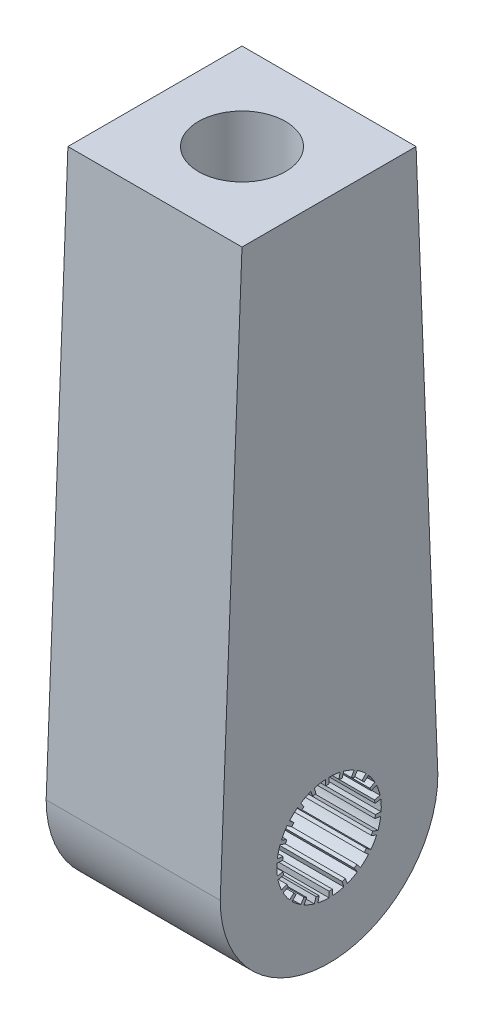
from build123d import *

# Parameters (mm, degrees)
SKETCH1_R           = 6
BOSS_EXTRUDE1_DEPTH = 20
SKETCH2_R           = 5
CUT_EXTRUDE1_DEPTH  = 50
BOSS_EXTRUDE2_DEPTH = 20


with BuildPart() as part:
    # Sketch1 → Boss-Extrude1 (new body)
    with BuildSketch(Plane(origin=(0, 0, 0), x_dir=(0, 0, -1), z_dir=(1, 0, 0))):
        with BuildLine():
            Line((10, 63.75), (0, 63.75))
            Line((0, 63.75), (-10, 63.75))
            Line((-10, 63.75), (-12.461612284, 0.978886756))
            Line((-12.461612284, 0.978886756), (-12.5, 0))
            ThreePointArc((-12.5, 0), (0, -12.5), (12.5, 0))
            Line((12.5, 0), (12.461612284, 0.978886756))
            Line((12.461612284, 0.978886756), (10, 63.75))
        make_face()
        Circle(SKETCH1_R, mode=Mode.SUBTRACT)
    extrude(amount=BOSS_EXTRUDE1_DEPTH)

    # Sketch2 → Cut-Extrude1 (cut)
    with BuildSketch(Plane(origin=(0, 63.75, 0), x_dir=(1, 0, 0), z_dir=(0, 1, 0))):
        with Locations(Location((10, 0, 0), (0, 0, 270))):
            Circle(SKETCH2_R)
    extrude(amount=-CUT_EXTRUDE1_DEPTH, mode=Mode.SUBTRACT)

    # Sketch3 → Boss-Extrude2 (add)
    with BuildSketch(Plane(origin=(20, 0, 0), x_dir=(0, 0, -1), z_dir=(1, 0, 0))):
        with BuildLine():
            ThreePointArc((0, 6), (-0.214106434, 5.996178653), (-0.427940142, 5.984719478))
            Line((-0.427940142, 5.984719478), (-0.380866727, 5.326400336))
            ThreePointArc((-0.380866727, 5.326400336), (-0.190554726, 5.336599001), (0, 5.34))
            Line((0, 5.34), (0, 6))
        make_face()
        with BuildLine():
            Line((-1.504451854, 5.123692479), (-1.690395341, 5.756957842))
            ThreePointArc((-1.690395341, 5.756957842), (-1.894752362, 5.692970533), (-2.09669588, 5.621731618))
            Line((-2.09669588, 5.621731618), (-1.866059333, 5.00334114))
            ThreePointArc((-1.866059333, 5.00334114), (-1.686329602, 5.066743774), (-1.504451854, 5.123692479))
        make_face()
        with BuildLine():
            ThreePointArc((1.690395341, 5.756957842), (1.483885124, 5.813612039), (1.275484761, 5.862860959))
            Line((1.275484761, 5.862860959), (1.135181437, 5.217946254))
            ThreePointArc((1.135181437, 5.217946254), (1.320657761, 5.174114715), (1.504451853, 5.123692479))
            Line((1.504451853, 5.123692479), (1.690395341, 5.756957842))
        make_face()
        with BuildLine():
            Line((-2.887021965, 4.492293865), (-3.243844905, 5.047521197))
            ThreePointArc((-3.243844905, 5.047521197), (-3.421896722, 4.928551798), (-3.595589788, 4.803304496))
            Line((-3.595589788, 4.803304496), (-3.200074911, 4.274941001))
            ThreePointArc((-3.200074911, 4.274941001), (-3.045488083, 4.3864111), (-2.887021965, 4.492293865))
        make_face()
        with BuildLine():
            ThreePointArc((3.243844904, 5.047521197), (3.061661135, 5.160061152), (2.875577474, 5.266028313))
            Line((2.875577474, 5.266028313), (2.559263952, 4.686765198))
            ThreePointArc((2.559263952, 4.686765198), (2.72487841, 4.592454426), (2.887021965, 4.492293866))
            Line((2.887021965, 4.492293866), (3.243844904, 5.047521197))
        make_face()
        with BuildLine():
            Line((-4.035702727, 3.496956319), (-4.534497446, 3.929164403))
            ThreePointArc((-4.534497446, 3.929164403), (-4.671819361, 3.764851107), (-4.803190394, 3.59574221))
            Line((-4.803190394, 3.59574221), (-4.274839451, 3.200210567))
            ThreePointArc((-4.274839451, 3.200210567), (-4.157919231, 3.350717485), (-4.035702727, 3.496956319))
        make_face()
        with BuildLine():
            ThreePointArc((4.534497446, 3.929164404), (4.391399568, 4.0884728), (4.242708003, 4.24257337))
            Line((4.242708003, 4.24257337), (3.776010122, 3.7758903))
            ThreePointArc((3.776010122, 3.7758903), (3.908345616, 3.638740792), (4.035702727, 3.49695632))
            Line((4.035702727, 3.49695632), (4.534497446, 3.929164404))
        make_face()
        with BuildLine():
            Line((-4.857434855, 2.218316169), (-5.457791972, 2.492490078))
            ThreePointArc((-5.457791972, 2.492490078), (-5.543258979, 2.29614457), (-5.621665081, 2.096874274))
            Line((-5.621665081, 2.096874274), (-5.003281922, 1.866218104))
            ThreePointArc((-5.003281922, 1.866218104), (-4.933500492, 2.043568668), (-4.857434855, 2.218316169))
        make_face()
        with BuildLine():
            ThreePointArc((5.457791972, 2.492490078), (5.365372925, 2.685660696), (5.266119561, 2.875410365))
            Line((5.266119561, 2.875410365), (4.686846409, 2.559115225))
            ThreePointArc((4.686846409, 2.559115225), (4.775181904, 2.390238019), (4.857434855, 2.21831617))
            Line((4.857434855, 2.21831617), (5.457791972, 2.492490078))
        make_face()
        with BuildLine():
            Line((-5.2856465, 0.759961236), (-5.938928651, 0.853889029))
            ThreePointArc((-5.938928651, 0.853889029), (-5.965616722, 0.641418056), (-5.984705895, 0.428130056))
            Line((-5.984705895, 0.428130056), (-5.326388247, 0.38103575))
            ThreePointArc((-5.326388247, 0.38103575), (-5.309398883, 0.57086207), (-5.2856465, 0.759961236))
        make_face()
        with BuildLine():
            ThreePointArc((5.938928651, 0.85388903), (5.904675677, 1.065272334), (5.862901431, 1.275298713))
            Line((5.862901431, 1.275298713), (5.217982274, 1.135015855))
            ThreePointArc((5.217982274, 1.135015855), (5.255161353, 0.948092378), (5.2856465, 0.759961237))
            Line((5.2856465, 0.759961237), (5.938928651, 0.85388903))
        make_face()
        with BuildLine():
            Line((-5.2856465, -0.759961237), (-5.938928651, -0.85388903))
            ThreePointArc((-5.938928651, -0.85388903), (-5.904675677, -1.065272334), (-5.862901431, -1.275298713))
            Line((-5.862901431, -1.275298713), (-5.217982274, -1.135015855))
            ThreePointArc((-5.217982274, -1.135015855), (-5.255161353, -0.948092378), (-5.2856465, -0.759961237))
        make_face()
        with BuildLine():
            ThreePointArc((5.938928651, -0.853889029), (5.965616722, -0.641418056), (5.984705895, -0.428130056))
            Line((5.984705895, -0.428130056), (5.326388247, -0.38103575))
            ThreePointArc((5.326388247, -0.38103575), (5.309398883, -0.57086207), (5.2856465, -0.759961236))
            Line((5.2856465, -0.759961236), (5.938928651, -0.853889029))
        make_face()
        with BuildLine():
            Line((-4.857434855, -2.21831617), (-5.457791972, -2.492490078))
            ThreePointArc((-5.457791972, -2.492490078), (-5.365372925, -2.685660696), (-5.266119561, -2.875410365))
            Line((-5.266119561, -2.875410365), (-4.686846409, -2.559115225))
            ThreePointArc((-4.686846409, -2.559115225), (-4.775181904, -2.390238019), (-4.857434855, -2.21831617))
        make_face()
        with BuildLine():
            ThreePointArc((5.457791972, -2.492490078), (5.543258979, -2.29614457), (5.621665081, -2.096874274))
            Line((5.621665081, -2.096874274), (5.003281922, -1.866218104))
            ThreePointArc((5.003281922, -1.866218104), (4.933500492, -2.043568668), (4.857434855, -2.218316169))
            Line((4.857434855, -2.218316169), (5.457791972, -2.492490078))
        make_face()
        with BuildLine():
            Line((-4.035702727, -3.49695632), (-4.534497446, -3.929164404))
            ThreePointArc((-4.534497446, -3.929164404), (-4.391399568, -4.0884728), (-4.242708003, -4.24257337))
            Line((-4.242708003, -4.24257337), (-3.776010122, -3.7758903))
            ThreePointArc((-3.776010122, -3.7758903), (-3.908345616, -3.638740792), (-4.035702727, -3.49695632))
        make_face()
        with BuildLine():
            ThreePointArc((4.534497446, -3.929164403), (4.671819361, -3.764851107), (4.803190394, -3.59574221))
            Line((4.803190394, -3.59574221), (4.274839451, -3.200210567))
            ThreePointArc((4.274839451, -3.200210567), (4.157919231, -3.350717485), (4.035702727, -3.496956319))
            Line((4.035702727, -3.496956319), (4.534497446, -3.929164403))
        make_face()
        with BuildLine():
            Line((-2.887021965, -4.492293866), (-3.243844904, -5.047521197))
            ThreePointArc((-3.243844904, -5.047521197), (-3.061661135, -5.160061152), (-2.875577474, -5.266028313))
            Line((-2.875577474, -5.266028313), (-2.559263952, -4.686765198))
            ThreePointArc((-2.559263952, -4.686765198), (-2.72487841, -4.592454426), (-2.887021965, -4.492293866))
        make_face()
        with BuildLine():
            ThreePointArc((3.243844905, -5.047521197), (3.421896722, -4.928551798), (3.595589788, -4.803304496))
            Line((3.595589788, -4.803304496), (3.200074911, -4.274941001))
            ThreePointArc((3.200074911, -4.274941001), (3.045488083, -4.3864111), (2.887021965, -4.492293865))
            Line((2.887021965, -4.492293865), (3.243844905, -5.047521197))
        make_face()
        with BuildLine():
            Line((-1.504451853, -5.123692479), (-1.690395341, -5.756957842))
            ThreePointArc((-1.690395341, -5.756957842), (-1.483885124, -5.813612039), (-1.275484761, -5.862860959))
            Line((-1.275484761, -5.862860959), (-1.135181437, -5.217946254))
            ThreePointArc((-1.135181437, -5.217946254), (-1.320657761, -5.174114715), (-1.504451853, -5.123692479))
        make_face()
        with BuildLine():
            ThreePointArc((1.690395341, -5.756957842), (1.894752362, -5.692970533), (2.09669588, -5.621731618))
            Line((2.09669588, -5.621731618), (1.866059333, -5.00334114))
            ThreePointArc((1.866059333, -5.00334114), (1.686329602, -5.066743774), (1.504451854, -5.123692479))
            Line((1.504451854, -5.123692479), (1.690395341, -5.756957842))
        make_face()
        with BuildLine():
            Line((0, -5.34), (0, -6))
            ThreePointArc((0, -6), (0.214106434, -5.996178653), (0.427940142, -5.984719478))
            Line((0.427940142, -5.984719478), (0.380866727, -5.326400336))
            ThreePointArc((0.380866727, -5.326400336), (0.190554726, -5.336599001), (0, -5.34))
        make_face()
    extrude(amount=-BOSS_EXTRUDE2_DEPTH)


solid = part.part
